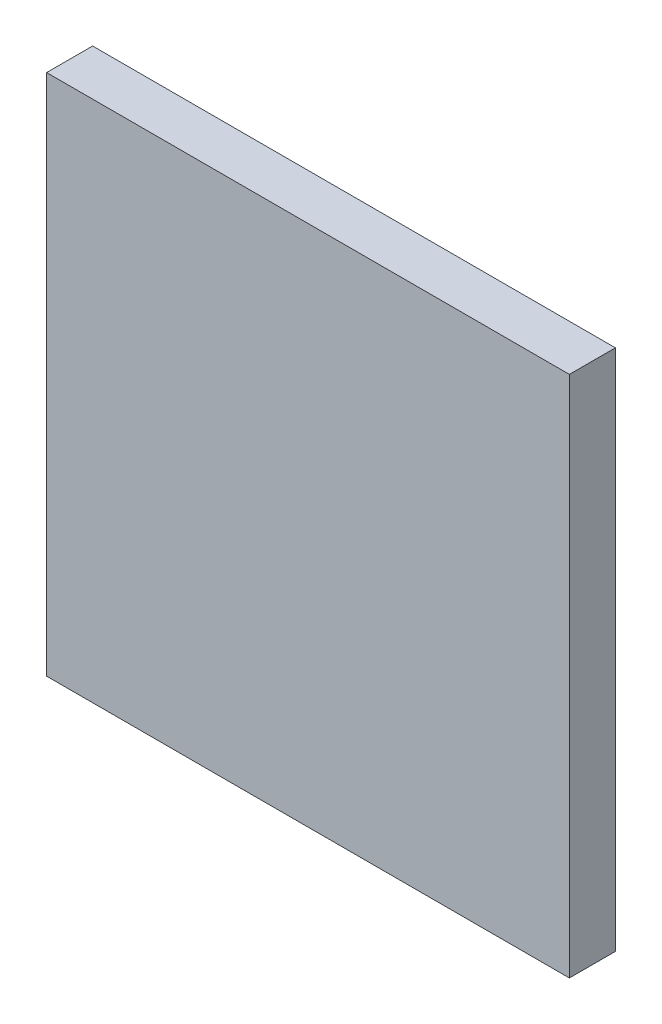
from build123d import *

# Parameters (mm, degrees)
SKETCH_1_W      = 12.5
SKETCH_1_H      = 12.5
EXTRUDE_1_DEPTH = 1.1


with BuildPart() as part:
    # 草图1 → 凸台-拉伸1 (new body)
    with BuildSketch(Plane.XY):
        Rectangle(SKETCH_1_W, SKETCH_1_H)
    extrude(amount=EXTRUDE_1_DEPTH)


solid = part.part
